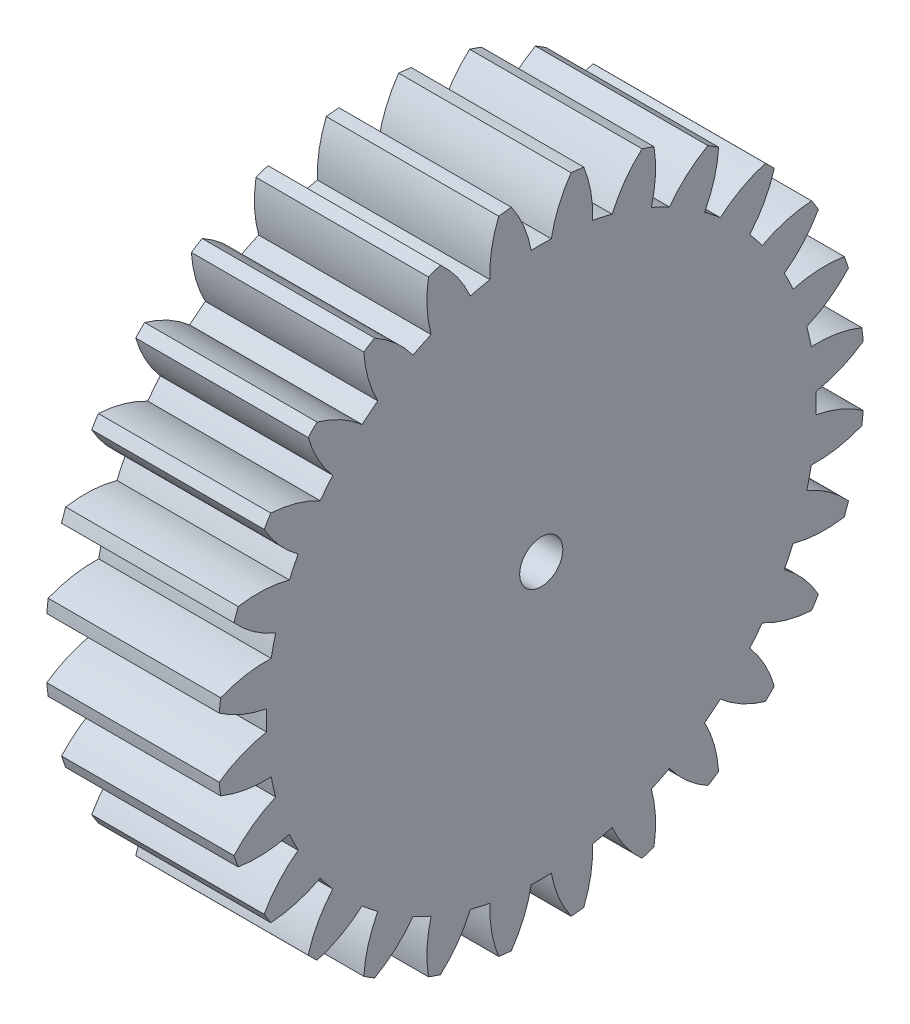
from build123d import *

# Parameters (mm, degrees)
BASPROSKE_W     = 20
BASPROSKE_H     = 37.5
TOOTHCUT_DEPTH  = 57.678920244
TEETHCUTS_COUNT = 28
TEETHCUTS_ANGLE = 347.142857143
BORSKE_R        = 2.5
BORE_DEPTH      = 50.0000508


with BuildPart() as part:
    # BasProSke → Base-Revolve (revolve)
    with BuildSketch(Plane(origin=(0, 0, 0), x_dir=(1, 0, 0), z_dir=(0, 1, 0)), mode=Mode.PRIVATE) as base_revolve_sk:
        with Locations((10, 18.75)):
            Rectangle(BASPROSKE_W, BASPROSKE_H)
    revolve(base_revolve_sk.sketch.rotate(Axis((-10, 0, 0), (1, 0, 0)), 180), axis=Axis((-10, 0, 0), (1, 0, 0)))

    # TooCutSke → ToothCut (cut, through all)
    with BuildSketch(Plane(origin=(0, 0, 0), x_dir=(0, 0, -1), z_dir=(1, 0, 0))):
        with BuildLine():
            ThreePointArc((1.165858694, 31.852670995), (0, 31.874), (-1.165858694, 31.852670995))
            ThreePointArc((-1.165858694, 31.852670995), (-2.027437167, 34.733177963), (-3.484179965, 37.363299307))
            ThreePointArc((-3.484179965, 37.363299307), (0, 37.5254), (3.484179965, 37.363299307))
            ThreePointArc((3.484179965, 37.363299307), (2.027437167, 34.733177963), (1.165858694, 31.852670995))
        make_face()
    toothcut = extrude(amount=TOOTHCUT_DEPTH, mode=Mode.SUBTRACT)

    # TeethCuts: ToothCut ×28 about axis
    teethcuts_axis = Axis((-10, 0, 0), (1, 0, 0))
    for i in range(1, TEETHCUTS_COUNT):
        add(toothcut.rotate(teethcuts_axis, i * TEETHCUTS_ANGLE / (TEETHCUTS_COUNT - 1)), mode=Mode.SUBTRACT)

    # BorSke → Bore (cut, symmetric)
    with BuildSketch(Plane(origin=(0, 0, 0), x_dir=(0, 0, -1), z_dir=(1, 0, 0))):
        with Locations(Location((0, 0, 0), (0, 0, 180))):
            Circle(BORSKE_R)
    extrude(amount=BORE_DEPTH, both=True, mode=Mode.SUBTRACT)


solid = part.part
